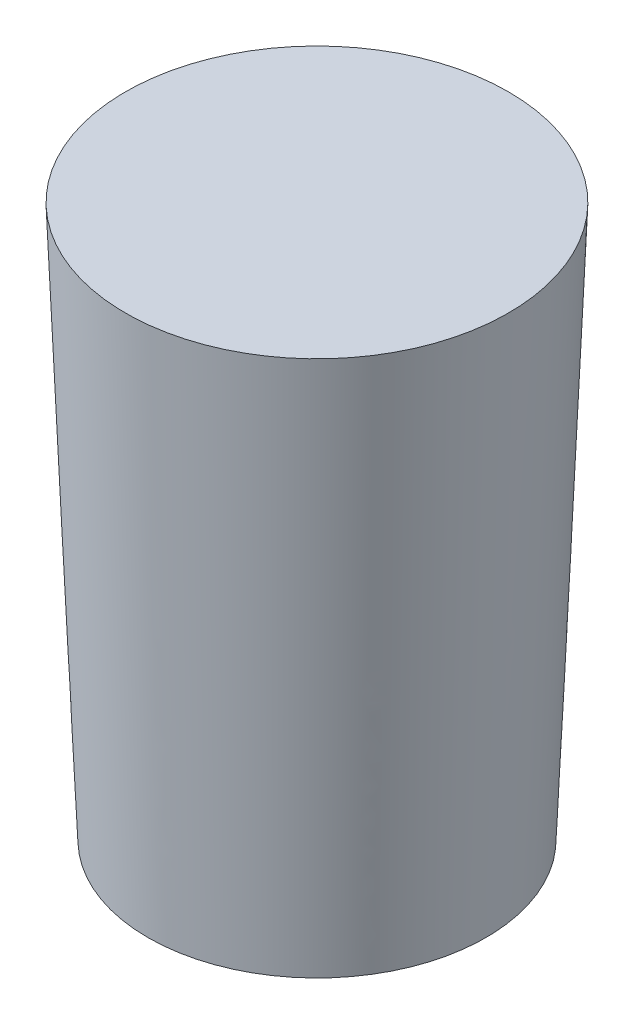
from build123d import *


with BuildPart() as part:
    # Skica1 → Rotovat1 (revolve)
    with BuildSketch(Plane.XY):
        with BuildLine():
            Line((0, 0), (0, 94))
            Line((0, 94), (-34, 94))
            add(Edge.make_bspline(
                [(-30, -4), (-32.096009342, 44.996086062), (-34, 94)],
                knots=[0, 0, 0, 1, 1, 1], degree=2))
            ThreePointArc((-30, -4), (-15.101142984, -1.241427621), (0, 0))
        make_face()
    revolve(axis=Axis((0, 0, 0), (0, 1, 0)))


solid = part.part
